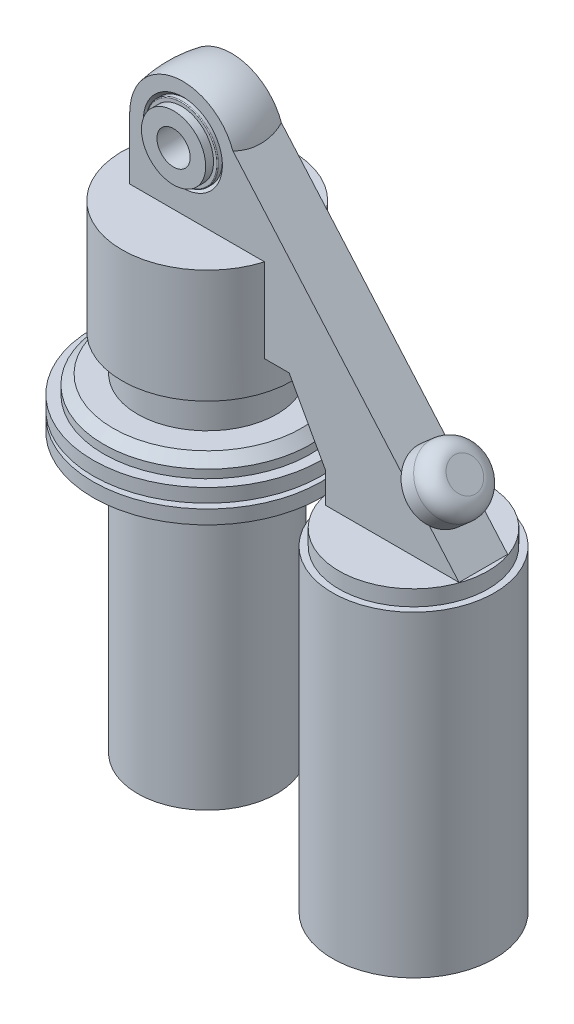
from build123d import *

# Parameters (mm, degrees)
EXTRUDE1_REACH             = 12.112
EXTRUDE1_DIRECTION_2_REACH = 12.088
SKETCH9_R                  = 9.730034016
EXTRUDE2_DEPTH             = 10
FILLET1_R                  = 5


with BuildPart() as part:
    # Sketch1 → Revolve1 (revolve)
    with BuildSketch(Plane(origin=(0, 0, 0), x_dir=(1, 0, 0), z_dir=(0, 1, 0))):
        with BuildLine():
            Line((5, 10.08849824), (5, -10.11150176))
            Line((5, -10.11150176), (9.65, -10.11150176))
            Line((9.65, -10.11150176), (9.65, -7.743710837))
            Line((9.65, -7.743710837), (10.623477626, -7.743710837))
            ThreePointArc((10.623477626, -7.743710837), (10.800254321, -7.670487532), (10.873477626, -7.493710837))
            Line((10.873477626, -7.493710837), (10.873477626, -6.327536233))
            Line((10.873477626, -6.327536233), (11.865828341, -7.31150176))
            Line((11.865828341, -7.31150176), (15.928234133, -7.31150176))
            ThreePointArc((15.928234133, -7.31150176), (16.6, -0.01150176), (15.928234133, 7.28849824))
            Line((15.928234133, 7.28849824), (11.865828341, 7.28849824))
            Line((11.865828341, 7.28849824), (10.873477626, 6.304532714))
            Line((10.873477626, 6.304532714), (10.873477626, 7.470707318))
            ThreePointArc((10.873477626, 7.470707318), (10.800254321, 7.647484013), (10.623477626, 7.720707318))
            Line((10.623477626, 7.720707318), (9.65, 7.720707318))
            Line((9.65, 7.720707318), (9.65, 10.08849824))
            Line((9.65, 10.08849824), (5, 10.08849824))
        make_face()
    revolve(axis=Axis((0, 0, -9.265426498), (0, 0, 1)))

    # Extrude1: up to this face of the body (flat: up to its plane)
    extrude1_end = Plane(part.part.faces().sort_by_distance((-12.316346835, 0, 7.31150176))[0])
    # Sketch2 → Extrude1 (add, up to the picked face)
    with BuildSketch(Plane.XY, mode=Mode.PRIVATE) as extrude1_sk1:
        with BuildLine():
            Line((-15, 0), (-16, 0))
            Line((-16, 0), (-16, -44))
            Line((-16, -44), (-0.071765867, -44))
            Line((-0.071765867, -44), (31.928234133, -44))
            Line((31.928234133, -44), (42.928234133, -64))
            Line((42.928234133, -64), (42.928234133, -73))
            Line((42.928234133, -73), (83, -73))
            Line((83, -73), (12.68857754, 8))
            ThreePointArc((12.68857754, 8), (4.163612428, -14.410563193), (-15, 0))
        make_face()
    extrude1_tool1 = split(extrude(extrude1_sk1.sketch, amount=EXTRUDE1_REACH, mode=Mode.PRIVATE), bisect_by=extrude1_end, keep=Keep.BOTH, mode=Mode.PRIVATE)
    add(extrude1_tool1.solids().sort_by_distance((27.055284, -37.225562, 0))[0])

    # Extrude1 direction 2: up to this face of the body (flat: up to its plane)
    extrude1_direction_2_end = Plane(part.part.faces().sort_by_distance((-15.477715638, 0, -7.28849824))[0])
    # Sketch2 → Extrude1 direction 2 (add, up to the picked face)
    with BuildSketch(Plane.XY, mode=Mode.PRIVATE) as extrude1_direction_2_sk1:
        with BuildLine():
            Line((-15, 0), (-16, 0))
            Line((-16, 0), (-16, -44))
            Line((-16, -44), (-0.071765867, -44))
            Line((-0.071765867, -44), (31.928234133, -44))
            Line((31.928234133, -44), (42.928234133, -64))
            Line((42.928234133, -64), (42.928234133, -73))
            Line((42.928234133, -73), (83, -73))
            Line((83, -73), (12.68857754, 8))
            ThreePointArc((12.68857754, 8), (4.163612428, -14.410563193), (-15, 0))
        make_face()
    extrude1_direction_2_tool1 = split(extrude(extrude1_direction_2_sk1.sketch, amount=-EXTRUDE1_DIRECTION_2_REACH, mode=Mode.PRIVATE), bisect_by=extrude1_direction_2_end, keep=Keep.BOTH, mode=Mode.PRIVATE)
    add(extrude1_direction_2_tool1.solids().sort_by_distance((27.055284, -37.225562, 0))[0])

    # Sketch5 → Revolve2 (revolve)
    with BuildSketch(Plane.XY):
        Polygon((-25.6, -18.8), (-25.6, -52.9), (-20.95, -52.9), (-20.95, -63.9), (-28.3, -63.9), (-31.1, -66.7), (-31.1, -69.2), (-34.3, -69.2), (-34.3, -73.3), (-30.4, -73.3), (-30.4, -74.8), (-34.3, -74.8), (-34.3, -78.95), (-20.95, -78.95), (-20.95, -162.65), (0, -162.65), (0, -18.8), align=None)
    revolve(axis=Axis((0, 0, 0), (0, -1, 0)))

    # Sketch9 → Extrude2 (add)
    with BuildSketch(Plane(origin=(33.351841584, -15.804444982, 0), x_dir=(0, 0, -1), z_dir=(0.755174719, 0.655523564, 0))):
        with Locations((0, -55.738174971)):
            Circle(SKETCH9_R)
    extrude(amount=EXTRUDE2_DEPTH)

    # Fillet1
    fillet1_edges = [part.edges().sort_by_distance(p)[0] for p in [
        (77.441275905, -51.341269972, 9.730034016),
    ]]
    fillet(fillet1_edges, radius=FILLET1_R)


with BuildPart() as body_2:
    # Sketch6 → Revolve3 (revolve)
    with BuildSketch(Plane.XY):
        Polygon((86.35, -172.9), (86.35, -77.7), (84.390298743, -77.7), (84.390298743, -73), (62, -73), (62, -178.224085177), (67.443541944, -178.224085177), (68.744234949, -176.549280333), (70.341835043, -176.549280333), (70.341835043, -173.101581518), (71.778065717, -173.101581518), (73.148819822, -169.398204306), (79.985017978, -169.398204306), (81.135152976, -172.309427526), (83.011694311, -172.309427526), (84.365727387, -171.37684084), (84.365727387, -172.9), align=None)
    revolve(axis=Axis((62, -208.539898489, 0), (0, 1, 0)))


solid = Compound([part.part, body_2.part])
